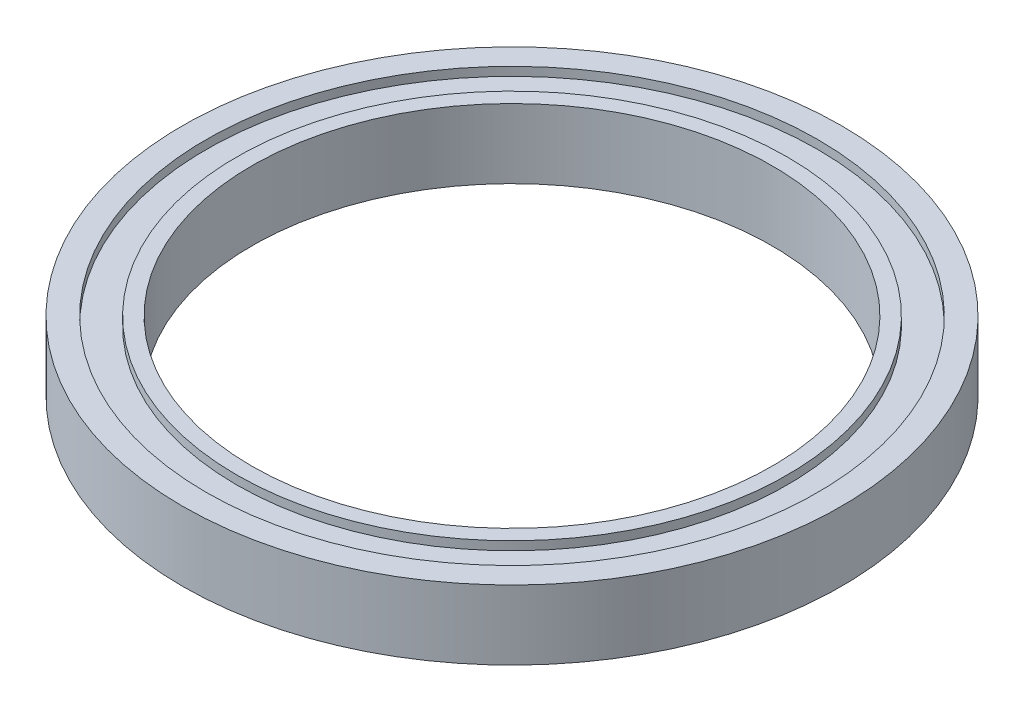
from build123d import *

# Parameters (mm, degrees)
SKETCH_1_R          = 38
SKETCH_1_R_2        = 30
EXTRUDE_1_DEPTH     = 8
SKETCH_2_R          = 35.25
SKETCH_2_R_2        = 31.75
CUT_EXTRUDE_1_DEPTH = 1
SKETCH_3_R          = 35.25
SKETCH_3_R_2        = 31.75
CUT_EXTRUDE_2_DEPTH = 1


with BuildPart() as part:
    # 草图1 → 凸台-拉伸1 (new body)
    with BuildSketch(Plane(origin=(0, 0, 0), x_dir=(1, 0, 0), z_dir=(0, 1, 0))):
        Circle(SKETCH_1_R)
        Circle(SKETCH_1_R_2, mode=Mode.SUBTRACT)
    extrude(amount=EXTRUDE_1_DEPTH)

    # 草图2 → 切除-拉伸1 (cut)
    with BuildSketch(Plane(origin=(0, 8, 0), x_dir=(1, 0, 0), z_dir=(0, 1, 0))):
        Circle(SKETCH_2_R)
        Circle(SKETCH_2_R_2, mode=Mode.SUBTRACT)
    extrude(amount=-CUT_EXTRUDE_1_DEPTH, mode=Mode.SUBTRACT)

    # 草图3 → 切除-拉伸2 (cut)
    with BuildSketch(Plane.XZ):
        Circle(SKETCH_3_R)
        Circle(SKETCH_3_R_2, mode=Mode.SUBTRACT)
    extrude(amount=-CUT_EXTRUDE_2_DEPTH, mode=Mode.SUBTRACT)


solid = part.part
